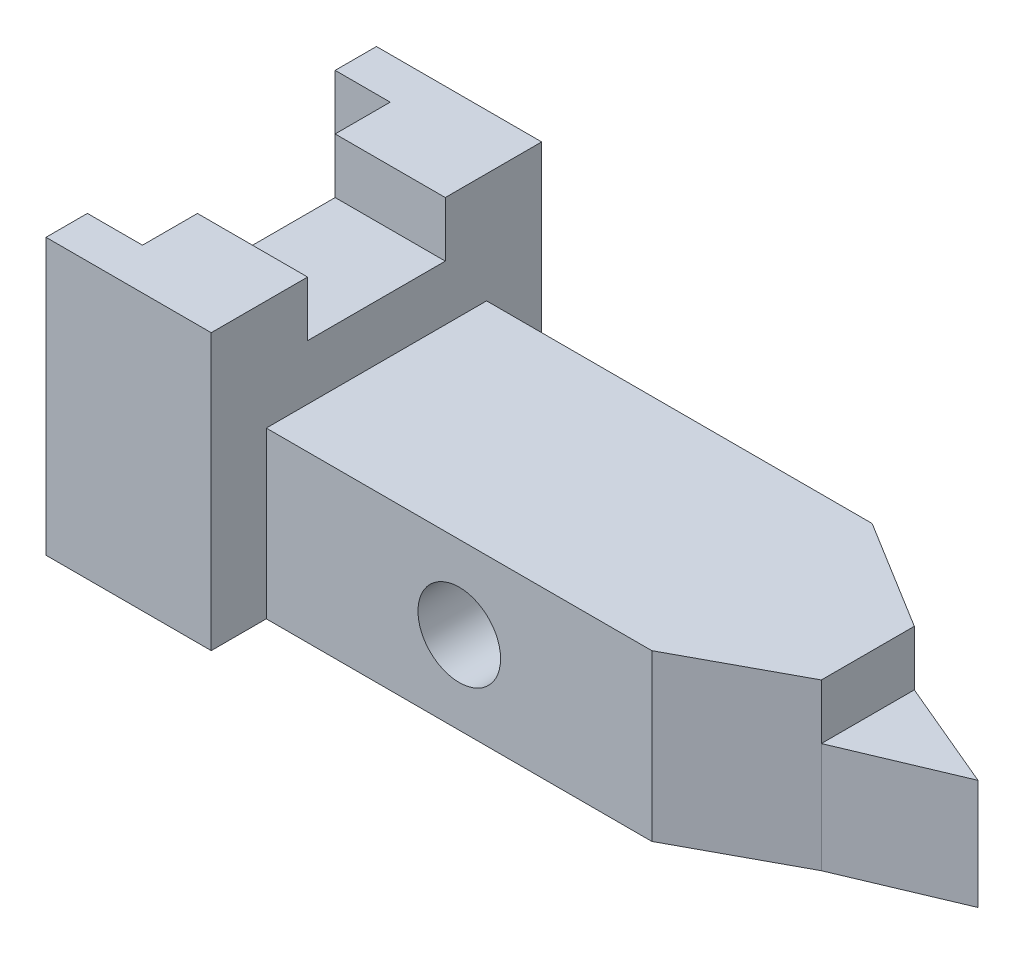
from build123d import *

# Parameters (mm, degrees)
SKETCH1_W           = 30
SKETCH1_H           = 60
BOSS_EXTRUDE1_DEPTH = 50
BOSS_EXTRUDE2_DEPTH = 90
SKETCH3_R           = 7.5
CUT_EXTRUDE1_DEPTH  = 90
CUT_EXTRUDE2_DEPTH  = 90
SKETCH5_W           = 16.87997937
SKETCH5_H           = 20
BOSS_EXTRUDE3_DEPTH = 20
CUT_EXTRUDE3_DEPTH  = 20
CUT_EXTRUDE4_DEPTH  = 10
SKETCH8_W           = 10
SKETCH8_H           = 44.983560701
CUT_EXTRUDE5_DEPTH  = 50


with BuildPart() as part:
    # Sketch1 → Boss-Extrude1 (new body)
    with BuildSketch(Plane(origin=(0, 0, 0), x_dir=(1, 0, 0), z_dir=(0, 1, 0))):
        with Locations((-15, -21.017964072)):
            Rectangle(SKETCH1_W, SKETCH1_H)
    extrude(amount=-BOSS_EXTRUDE1_DEPTH)

    # Sketch2 → Boss-Extrude2 (add)
    with BuildSketch(Plane(origin=(0, 0, 0), x_dir=(0, 0, -1), z_dir=(1, 0, 0))):
        Polygon((-21.017964072, -50), (-41.017964072, -50), (-41.017964072, -20), (-1.017964072, -20), (-1.017964072, -50), align=None)
    extrude(amount=BOSS_EXTRUDE2_DEPTH)

    # Sketch3 → Cut-Extrude1 (cut)
    with BuildSketch(Plane.XY.offset(41.017964072)):
        with Locations((35.036901586, -35)):
            Circle(SKETCH3_R)
    extrude(amount=-CUT_EXTRUDE1_DEPTH, mode=Mode.SUBTRACT)

    # Sketch4 → Cut-Extrude2 (cut)
    with BuildSketch(Plane(origin=(0, -20, 0), x_dir=(1, 0, 0), z_dir=(0, 1, 0))):
        Polygon((70, -1.017964072), (90, -13.353113833), (90, -1.017964072), align=None)
        Polygon((70, -41.017964072), (90, -30.233093203), (90, -41.017964072), align=None)
    extrude(amount=-CUT_EXTRUDE2_DEPTH, mode=Mode.SUBTRACT)

    # Sketch5 → Boss-Extrude3 (add)
    with BuildSketch(Plane(origin=(90, 0, 0), x_dir=(0, 0, -1), z_dir=(1, 0, 0))):
        with Locations((-21.793103518, -40)):
            Rectangle(SKETCH5_W, SKETCH5_H)
    extrude(amount=BOSS_EXTRUDE3_DEPTH)

    # Sketch6 → Cut-Extrude3 (cut)
    with BuildSketch(Plane(origin=(0, -30, 0), x_dir=(1, 0, 0), z_dir=(0, 1, 0))):
        Polygon((110, -13.353113833), (90, -13.353113833), (110, -21.793103518), align=None)
        Polygon((110, -30.233093203), (110, -21.793103518), (90, -30.233093203), align=None)
    extrude(amount=-CUT_EXTRUDE3_DEPTH, mode=Mode.SUBTRACT)

    # Sketch7 → Cut-Extrude4 (cut)
    with BuildSketch(Plane(origin=(0, 0, 0), x_dir=(1, 0, 0), z_dir=(0, 1, 0))):
        Polygon((-30, 1.482035928), (-30, -43.501524773), (-20, -43.501524773), (-20, -33.517964072), (0, -33.517964072), (0, -8.517964072), (-20, -8.517964072), (-20, 1.482035928), align=None)
    extrude(amount=-CUT_EXTRUDE4_DEPTH, mode=Mode.SUBTRACT)

    # Sketch8 → Cut-Extrude5 (cut)
    with BuildSketch(Plane(origin=(0, -10, 0), x_dir=(1, 0, 0), z_dir=(0, 1, 0))):
        with Locations((-25, -21.009744422)):
            Rectangle(SKETCH8_W, SKETCH8_H)
    extrude(amount=-CUT_EXTRUDE5_DEPTH, mode=Mode.SUBTRACT)


solid = part.part
